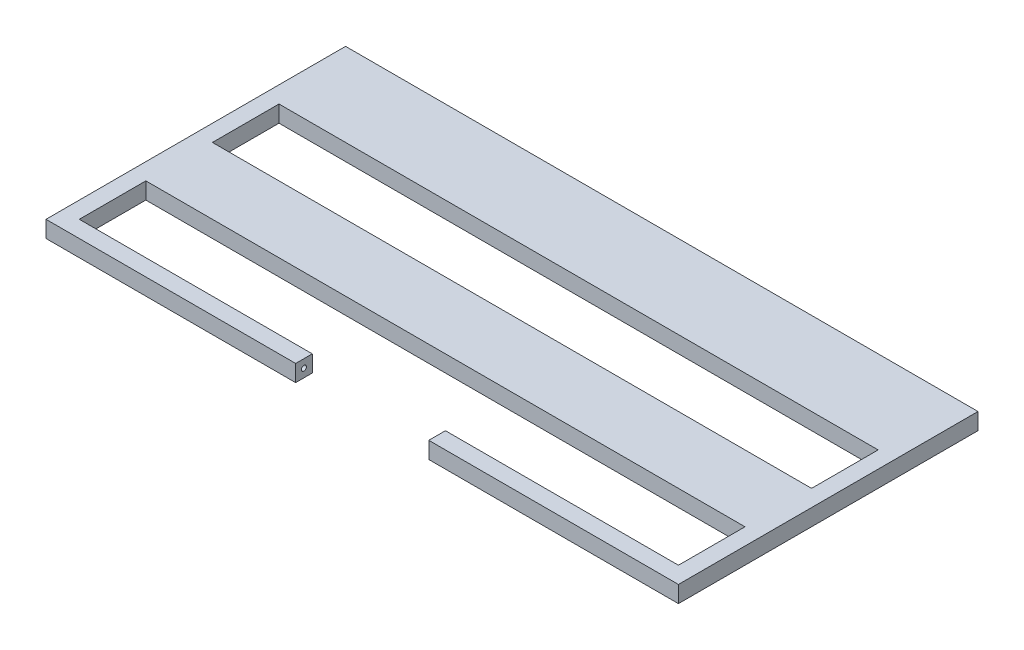
from build123d import *

# Parameters (mm, degrees)
CROQUIS1_W              = 900
CROQUIS1_H              = 100
CROQUIS1_H_2            = 150
SALIENTE_EXTRUIR2_DEPTH = 25
CORTAR_EXTRUIR1_DEPTH   = 10
CROQUIS3_W              = 950
CROQUIS3_H              = 25
CORTAR_EXTRUIR2_DEPTH   = 750


with BuildPart() as part:
    # Croquis1 → Saliente-Extruir2 (new body)
    with BuildSketch(Plane(origin=(0, 0, 0), x_dir=(1, 0, 0), z_dir=(0, 1, 0))):
        Polygon((450, -475), (450, -575), (100, -575), (100, -600), (475, -600), (475, 600), (-475, 600), (-475, -600), (-100, -600), (-100, -575), (-450, -575), (-450, -475), align=None)
        with Locations((0, -325)):
            Rectangle(CROQUIS1_W, CROQUIS1_H, mode=Mode.SUBTRACT)
        with Locations((0, 50)):
            Rectangle(CROQUIS1_W, CROQUIS1_H_2, mode=Mode.SUBTRACT)
        with Locations((0, 350)):
            Rectangle(CROQUIS1_W, CROQUIS1_H_2, mode=Mode.SUBTRACT)
    extrude(amount=SALIENTE_EXTRUIR2_DEPTH)

    # Croquis2 → Cortar-Extruir1 (cut)
    with BuildSketch(Plane(origin=(-100, 0, 0), x_dir=(0, 0, -1), z_dir=(1, 0, 0))):
        with BuildLine():
            ThreePointArc((-583.75, 12.5), (-586.064937129, 15.964548247), (-590.151650429, 15.151650429))
            Line((-590.151650429, 15.151650429), (-584.848349571, 9.848349571))
            ThreePointArc((-584.848349571, 9.848349571), (-584.035451753, 11.064937129), (-583.75, 12.5))
        make_face()
        with BuildLine():
            Line((-584.848349571, 9.848349571), (-590.151650429, 15.151650429))
            ThreePointArc((-590.151650429, 15.151650429), (-590.151650429, 9.848349571), (-584.848349571, 9.848349571))
        make_face()
    extrude(amount=-CORTAR_EXTRUIR1_DEPTH, mode=Mode.SUBTRACT)

    # Croquis3 → Cortar-Extruir2 (cut)
    with BuildSketch(Plane(origin=(0, 0, -600), x_dir=(-1, 0, 0), z_dir=(0, 0, -1))):
        with Locations((0, 12.5)):
            Rectangle(CROQUIS3_W, CROQUIS3_H)
    extrude(amount=-CORTAR_EXTRUIR2_DEPTH, mode=Mode.SUBTRACT)


solid = part.part
